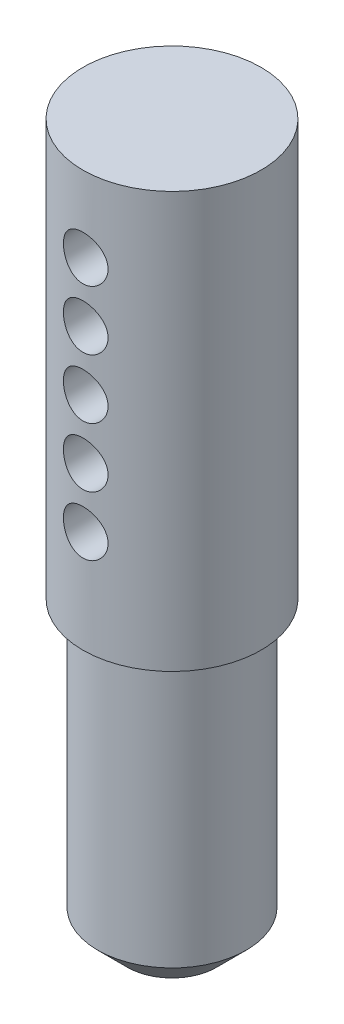
from build123d import *

# Parameters (mm, degrees)
SKETCH2_R          = 2.3876
CUT_EXTRUDE1_DEPTH = 18.161


with BuildPart() as part:
    # Sketch1 → Revolve1 (revolve)
    with BuildSketch(Plane.XY):
        Polygon((0, 0), (9.525, 0), (9.525, -44.45), (7.9375, -44.45), (7.9375, -73.025), (4.7625, -76.2), (0, -76.2), align=None)
    revolve(axis=Axis((0, 76.054523893, 0), (0, -1, 0)))

    # Sketch2 → Cut-Extrude1 (cut, symmetric)
    with BuildSketch(Plane.XY):
        with Locations((0, -8.128)):
            Circle(SKETCH2_R)
        with Locations((0, -14.478)):
            Circle(SKETCH2_R)
        with Locations((0, -20.828)):
            Circle(SKETCH2_R)
        with Locations((0, -27.178)):
            Circle(SKETCH2_R)
        with Locations((0, -33.528)):
            Circle(SKETCH2_R)
    extrude(amount=CUT_EXTRUDE1_DEPTH, both=True, mode=Mode.SUBTRACT)


solid = part.part
